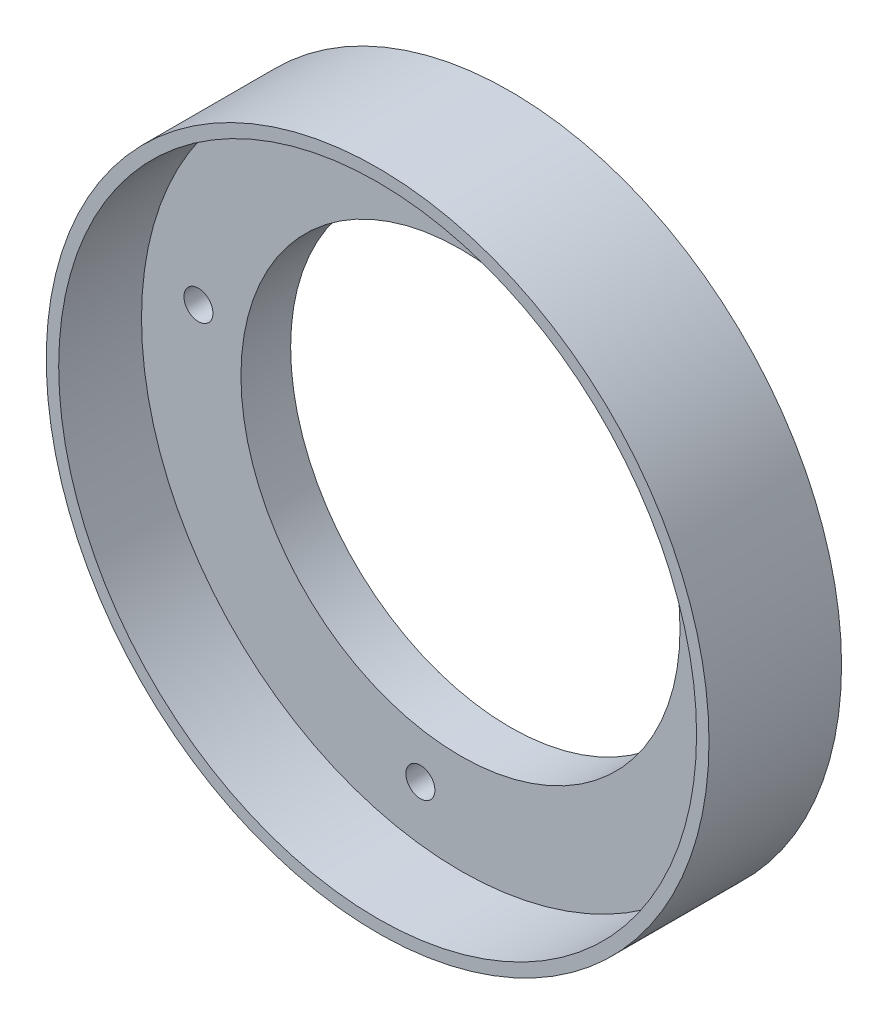
from build123d import *

# Parameters (mm, degrees)
SKETCH1_R           = 40
SKETCH1_R_2         = 26.5
BOSS_EXTRUDE1_DEPTH = 6
SKETCH2_R           = 1.75
CUT_EXTRUDE1_DEPTH  = 7
SKETCH3_R           = 40
SKETCH3_R_2         = 38.5
BOSS_EXTRUDE2_DEPTH = 10


with BuildPart() as part:
    # Sketch1 → Boss-Extrude1 (new body)
    with BuildSketch(Plane.XY):
        Circle(SKETCH1_R)
        Circle(SKETCH1_R_2, mode=Mode.SUBTRACT)
    extrude(amount=BOSS_EXTRUDE1_DEPTH)

    # Sketch2 → Cut-Extrude1 (cut, through all)
    with BuildSketch(Plane.XY.offset(6)):
        with Locations((-31.631941874, 4.839447619)):
            Circle(SKETCH2_R)
        with Locations((4.839447619, 31.631941874)):
            Circle(SKETCH2_R)
        with Locations((31.631941874, -4.839447619)):
            Circle(SKETCH2_R)
        with Locations((-4.839447619, -31.631941874)):
            Circle(SKETCH2_R)
    extrude(amount=-CUT_EXTRUDE1_DEPTH, mode=Mode.SUBTRACT)

    # Sketch3 → Boss-Extrude2 (add)
    with BuildSketch(Plane.XY.offset(6)):
        Circle(SKETCH3_R)
        Circle(SKETCH3_R_2, mode=Mode.SUBTRACT)
    extrude(amount=BOSS_EXTRUDE2_DEPTH)


solid = part.part
